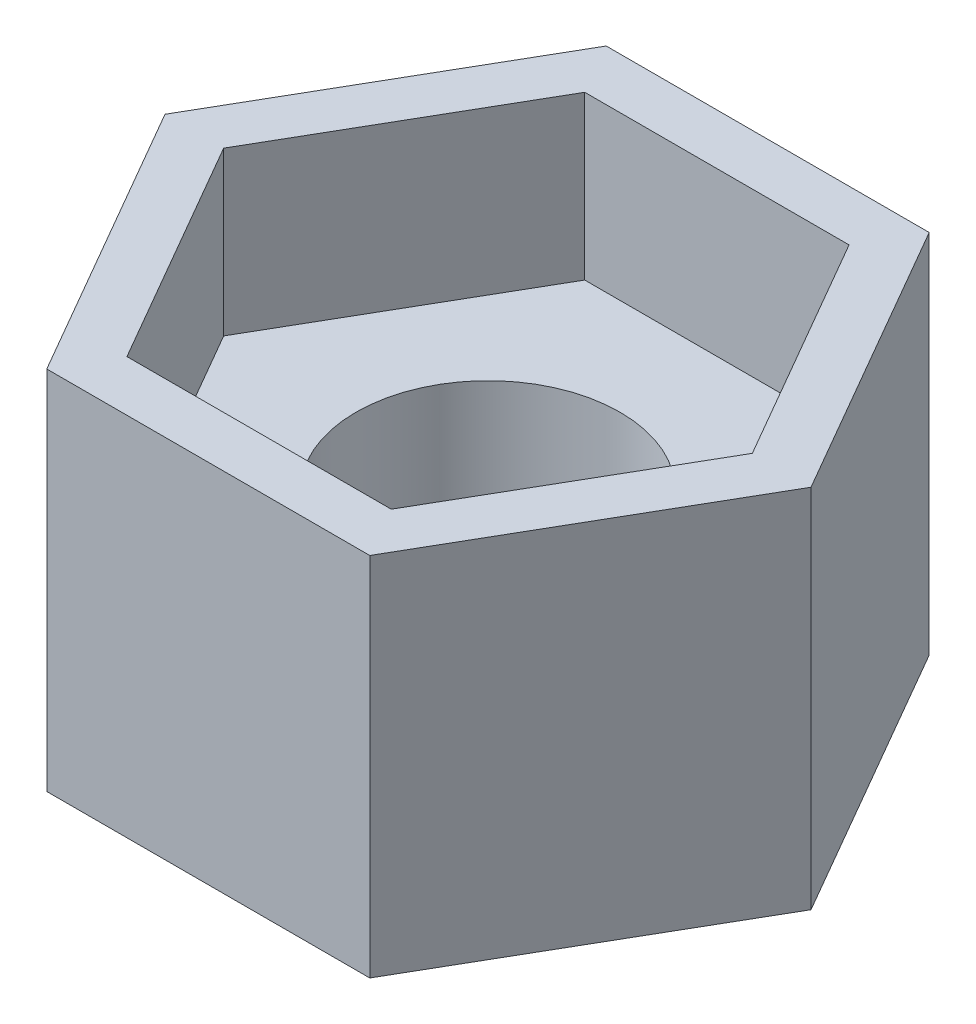
from build123d import *

# Parameters (mm, degrees)
BOSS_EXTRUDE1_DEPTH = 1
BOSS_EXTRUDE2_DEPTH = 1.6
SKETCH2_R           = 1.3
CUT_EXTRUDE1_DEPTH  = 2.6
BOSS_EXTRUDE3_START = 1
SKETCH3_R           = 1.3
BOSS_EXTRUDE3_DEPTH = 1


with BuildPart() as part:
    # Sketch1 → Boss-Extrude1 (new body)
    with BuildSketch(Plane(origin=(0, 0, 0), x_dir=(1, 0, 0), z_dir=(0, 1, 0))):
        Polygon((1.588897275, -2.752050808), (3.177794549, 0), (1.588897275, 2.752050808), (-1.588897275, 2.752050808), (-3.177794549, 0), (-1.588897275, -2.752050808), align=None)
    extrude(amount=-BOSS_EXTRUDE1_DEPTH)

    # Sketch1_3 → Boss-Extrude2 (add)
    with BuildSketch(Plane(origin=(0, 0, 0), x_dir=(1, 0, 0), z_dir=(0, 1, 0))):
        Polygon((1.588897275, -2.752050808), (3.177794549, 0), (1.588897275, 2.752050808), (-1.588897275, 2.752050808), (-3.177794549, 0), (-1.588897275, -2.752050808), align=None)
        Polygon((2.60044428, 0), (1.30022214, -2.252050808), (-1.30022214, -2.252050808), (-2.60044428, 0), (-1.30022214, 2.252050808), (1.30022214, 2.252050808), align=None, mode=Mode.SUBTRACT)
    extrude(amount=BOSS_EXTRUDE2_DEPTH)

    # Sketch2 → Cut-Extrude1 (cut)
    with BuildSketch(Plane.XZ.offset(1)):
        Circle(SKETCH2_R)
    extrude(amount=-CUT_EXTRUDE1_DEPTH, mode=Mode.SUBTRACT)

    # Sketch3 → Boss-Extrude3 (add)
    with BuildSketch(Plane.XZ.offset(1).offset(BOSS_EXTRUDE3_START)):
        Polygon((-1.588897275, -2.752050808), (1.588897275, -2.752050808), (3.177794549, 0), (1.588897275, 2.752050808), (-1.588897275, 2.752050808), (-3.177794549, 0), align=None)
        Circle(SKETCH3_R, mode=Mode.SUBTRACT)
    extrude(amount=-BOSS_EXTRUDE3_DEPTH)


solid = part.part
